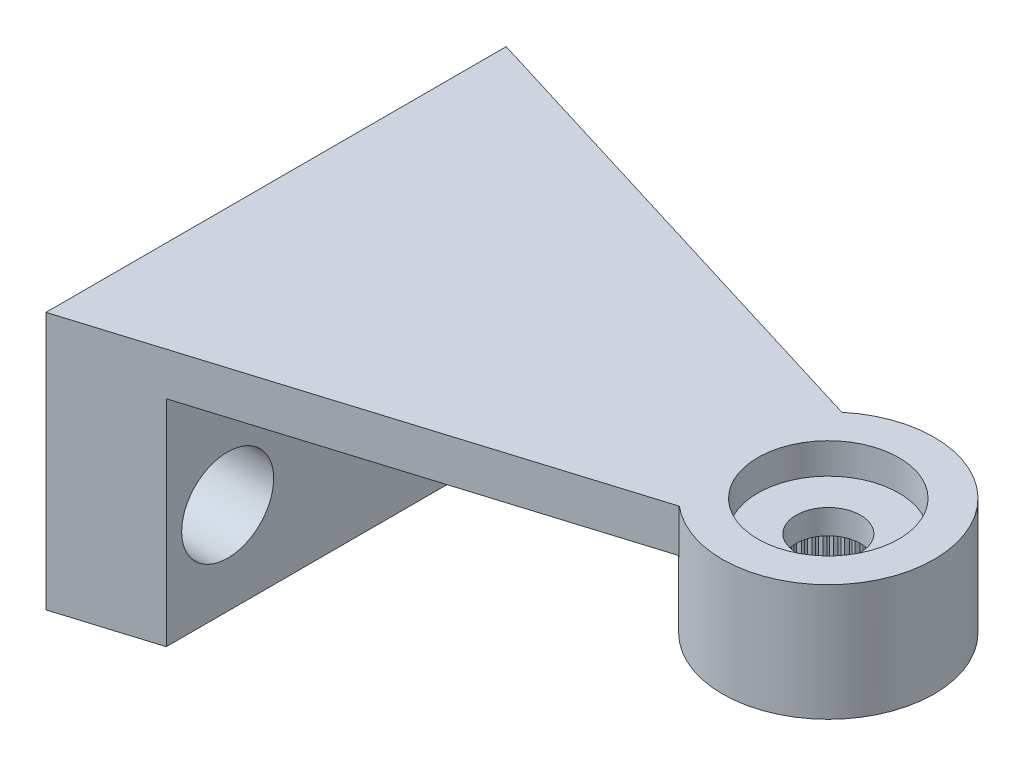
from build123d import *

# Parameters (mm, degrees)
RESSALTO_EXTRUS_O1_DEPTH = 1.4
ESBO_O2_R                = 3.45
RESSALTO_EXTRUS_O2_DEPTH = 2.4
FURO1_D                  = 4.95
FURO1_DEPTH              = 2
FURO2_D                  = 4.6
FURO2_DEPTH              = 1
FURO3_D                  = 2.1
RESSALTO_EXTRUS_O3_DEPTH = 2
PADR_OCIRCULAR1_COUNT    = 60
BOSS_EXTRUDE1_DEPTH      = 7
CUT_EXTRUDE1_REACH       = 5
SKETCH2_R                = 1.5


with BuildPart() as part:
    # Esboço1 → Ressalto-extrusão1 (new body)
    with BuildSketch(Plane(origin=(0, 0, 0), x_dir=(1, 0, 0), z_dir=(0, 1, 0))):
        with BuildLine():
            Line((-18, 7.5), (-2.209072203, 2.65))
            ThreePointArc((-2.209072203, 2.65), (3.45, 0), (-2.209072203, -2.65))
            Line((-2.209072203, -2.65), (-18, -7.5))
            Line((-18, -7.5), (-18, 7.5))
        make_face()
    extrude(amount=-RESSALTO_EXTRUS_O1_DEPTH)

    # Esboço2 → Ressalto-extrusão2 (add)
    with BuildSketch(Plane.XZ.offset(1.4)):
        Circle(ESBO_O2_R)
    extrude(amount=RESSALTO_EXTRUS_O2_DEPTH)

    # Furo1
    with Locations(Plane(origin=(0, -3.8, 0), x_dir=(-1, 0, 0), z_dir=(0, -1, 0))):
        with Locations((0, 0)):
            Hole(FURO1_D / 2, depth=FURO1_DEPTH)

    # Furo2
    with Locations(Plane(origin=(0, 0, 0), x_dir=(1, 0, 0), z_dir=(0, 1, 0))):
        with Locations((0, 0)):
            Hole(FURO2_D / 2, depth=FURO2_DEPTH)

    # Furo3 (through all)
    with Locations(Plane(origin=(0, 0, 0), x_dir=(1, 0, 0), z_dir=(0, 1, 0))):
        with Locations((0, 0)):
            Hole(FURO3_D / 2)

    # Esboço11 → Ressalto-extrusão3 (add)
    with BuildSketch(Plane.XZ.offset(3.8)):
        with BuildLine():
            Line((-0.098056786, 2.473056786), (0, 2.375))
            Line((0, 2.375), (0.098056786, 2.473056786))
            ThreePointArc((0.098056786, 2.473056786), (0, 2.475), (-0.098056786, 2.473056786))
        make_face()
    ressalto_extrus_o3 = extrude(amount=-RESSALTO_EXTRUS_O3_DEPTH)

    # PadrãoCircular1: Ressalto-extrusão3 ×60 about axis
    padr_ocircular1_axis = Axis((0, 0, 0), (0, 1, 0))
    for i in range(1, PADR_OCIRCULAR1_COUNT):
        add(ressalto_extrus_o3.rotate(padr_ocircular1_axis, i * 360 / PADR_OCIRCULAR1_COUNT))

    # Sketch1 → Boss-Extrude1 (add)
    with BuildSketch(Plane.XZ.offset(1.4)):
        Polygon((-18, 7.5), (-15, 6.578584857), (-15, -6.578584857), (-18, -7.5), align=None)
    extrude(amount=BOSS_EXTRUDE1_DEPTH)

    # Sketch2 → Cut-Extrude1 (cut, up to next)
    with BuildSketch(Plane(origin=(-15, 0, 0), x_dir=(0, 0, -1), z_dir=(1, 0, 0)), mode=Mode.PRIVATE) as cut_extrude1_sk1:
        with Locations((4.578584857, -5.4)):
            Circle(SKETCH2_R)
    cut_extrude1_tool1 = extrude(cut_extrude1_sk1.sketch, amount=-CUT_EXTRUDE1_REACH, mode=Mode.PRIVATE) & part.part
    add(cut_extrude1_tool1.solids().sort_by_distance((-15, -5.4, -4.578585))[0], mode=Mode.SUBTRACT)
    # Sketch2 → Cut-Extrude1 (cut, up to next)
    with BuildSketch(Plane(origin=(-15, 0, 0), x_dir=(0, 0, -1), z_dir=(1, 0, 0)), mode=Mode.PRIVATE) as cut_extrude1_sk2:
        with Locations((-4.578584857, -5.4)):
            Circle(SKETCH2_R)
    cut_extrude1_tool2 = extrude(cut_extrude1_sk2.sketch, amount=-CUT_EXTRUDE1_REACH, mode=Mode.PRIVATE) & part.part
    add(cut_extrude1_tool2.solids().sort_by_distance((-15, -5.4, 4.578585))[0], mode=Mode.SUBTRACT)


solid = part.part
